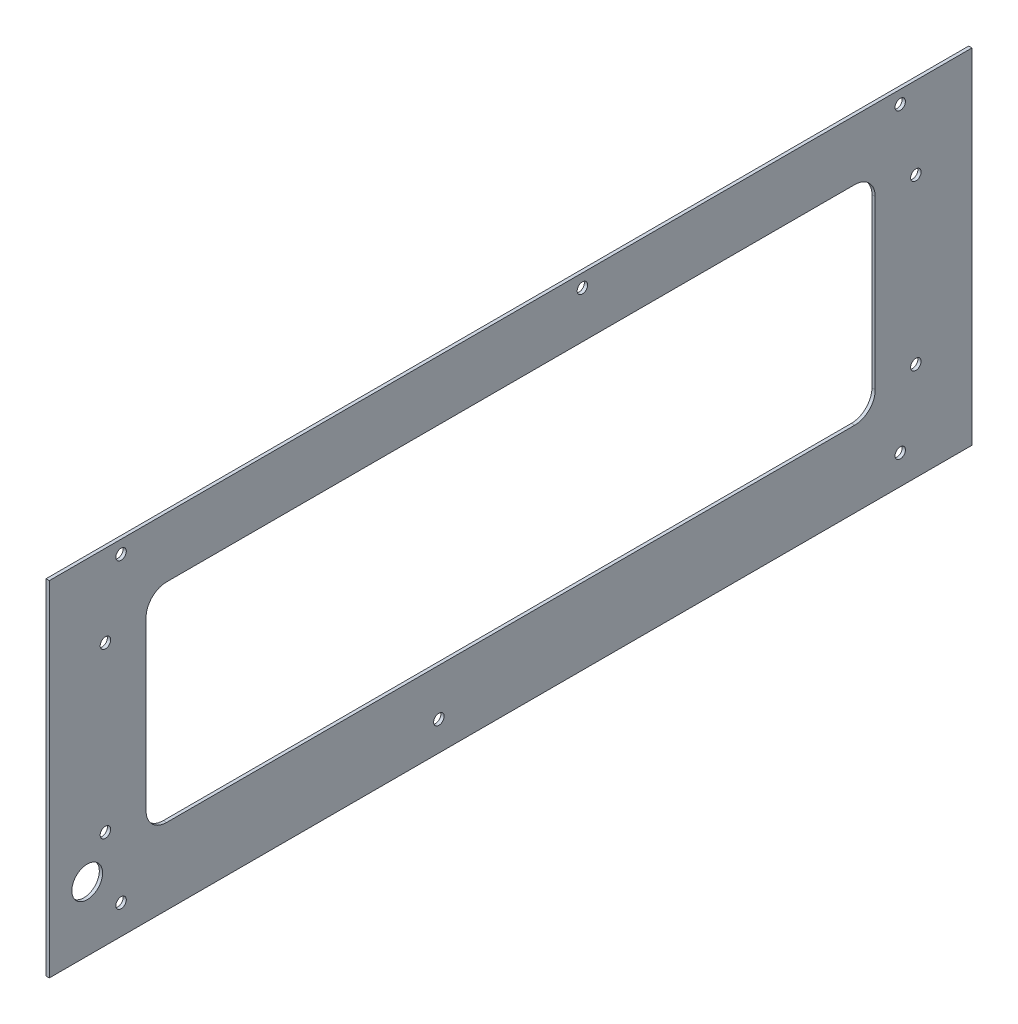
from build123d import *

# Parameters (mm, degrees)
SKETCH1_W                  = 450
SKETCH1_H                  = 167.8324167
BOSS_EXTRUDE1_DEPTH        = 1.6002
F_10_CLEARANCE_HOLE1_D     = 5.1054
F_10_CLEARANCE_HOLE1_DEPTH = 129.53
F_10_CLEARANCE_HOLE1_TIP   = 1.533816902
SKETCH4_R                  = 7.5
CUT_EXTRUDE1_DEPTH         = 2.6002
SKETCH5_W                  = 355.6
SKETCH5_H                  = 101.6
CUT_EXTRUDE2_DEPTH         = 2.6002
FILLET1_R                  = 10
F_10_CLEARANCE_HOLE2_D     = 5.1054
MIRROR2_COPY_1_D           = 5.1054


with BuildPart() as part:
    # Sketch1 → Boss-Extrude1 (new body)
    with BuildSketch(Plane(origin=(0, 0, 0), x_dir=(0, 0, -1), z_dir=(1, 0, 0))):
        with Locations((0, -3.9624)):
            Rectangle(SKETCH1_W, SKETCH1_H)
    extrude(amount=BOSS_EXTRUDE1_DEPTH)

    # #10 Clearance Hole1
    with Locations(Plane(origin=(1.6002, 0, 0), x_dir=(0, 0, -1), z_dir=(1, 0, 0))):
        with Locations((-190, 73.59110835), (35, 73.59110835), (-35, -73.59110835), (-190, -73.59110835), (190, 73.59110835), (190, -73.59110835)):
            Hole(F_10_CLEARANCE_HOLE1_D / 2, depth=F_10_CLEARANCE_HOLE1_DEPTH)
            with Locations((0, 0, -(F_10_CLEARANCE_HOLE1_DEPTH + F_10_CLEARANCE_HOLE1_TIP / 2))):  # 118° drill point
                Cone(0, F_10_CLEARANCE_HOLE1_D / 2, F_10_CLEARANCE_HOLE1_TIP, mode=Mode.SUBTRACT)

    # Sketch4 → Cut-Extrude1 (cut, through all)
    with BuildSketch(Plane(origin=(1.6002, 0, 0), x_dir=(0, 0, -1), z_dir=(1, 0, 0))):
        with Locations((-206.5, -56.5321)):
            Circle(SKETCH4_R)
    extrude(amount=-CUT_EXTRUDE1_DEPTH, mode=Mode.SUBTRACT)

    # Sketch5 → Cut-Extrude2 (cut, through all)
    with BuildSketch(Plane(origin=(1.6002, 0, 0), x_dir=(0, 0, -1), z_dir=(1, 0, 0))):
        Rectangle(SKETCH5_W, SKETCH5_H)
    extrude(amount=-CUT_EXTRUDE2_DEPTH, mode=Mode.SUBTRACT)

    # Fillet1
    fillet1_edges = [part.edges().sort_by_distance(p)[0] for p in [
        (0.8001, -50.8, 177.8),
        (0.8001, 50.8, 177.8),
        (0.8001, 50.8, -177.8),
        (0.8001, -50.8, -177.8),
    ]]
    fillet(fillet1_edges, radius=FILLET1_R)

    # #10 Clearance Hole2 (through all)
    with Locations(Plane(origin=(1.6002, 0, 0), x_dir=(0, 0, -1), z_dir=(1, 0, 0))):
        with Locations((197.627, 40)):
            f_10_clearance_hole2 = Hole(F_10_CLEARANCE_HOLE2_D / 2)

    # Mirror1: #10 Clearance Hole2 across plane
    add(f_10_clearance_hole2.mirror(Plane.ZX), mode=Mode.SUBTRACT)

    # Mirror2: #10 Clearance Hole2 across plane
    add(f_10_clearance_hole2.mirror(Plane.XY), mode=Mode.SUBTRACT)

    # Mirror2 copy 1 (through all)
    with Locations(Plane(origin=(1.6002, 0, 0), x_dir=(0, 0, 1), z_dir=(1, 0, 0))):
        with Locations((197.627, 40)):
            Hole(MIRROR2_COPY_1_D / 2)


solid = part.part
